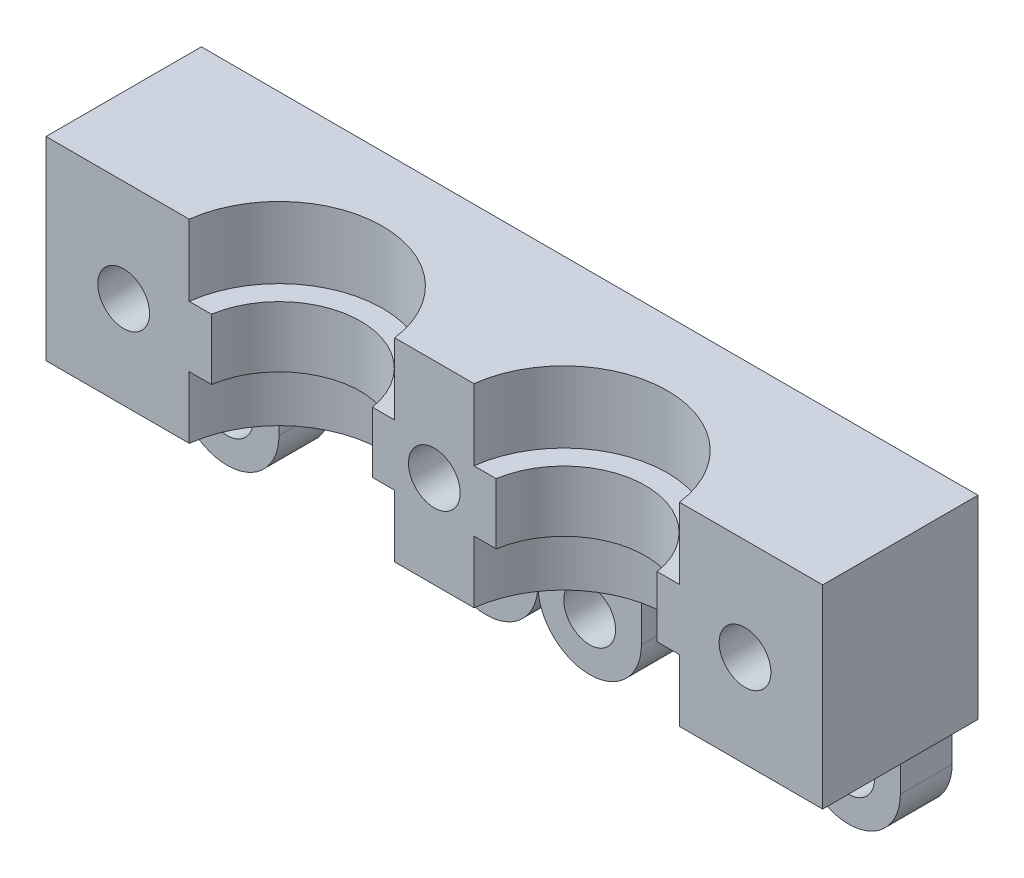
from build123d import *

# Parameters (mm, degrees)
SCHIZZO1_W                   = 60
SCHIZZO1_H                   = 30
ESTRUSIONE_ESTRUSIONE1_DEPTH = 5
SCHIZZO2_W                   = 60
SCHIZZO2_H                   = 8
ESTRUSIONE_ESTRUSIONE2_DEPTH = 20
SCHIZZO3_R                   = 5
TAGLIO_ESTRUSIONE1_DEPTH     = 8
RACCORDO1_R                  = 20
SCHIZZO4_W                   = 60
SCHIZZO4_H                   = 15
ESTRUSIONE_ESTRUSIONE3_DEPTH = 10
SCHIZZO6_R                   = 8
TAGLIO_ESTRUSIONE2_DEPTH     = 15
SCHIZZO8_W                   = 60
SCHIZZO8_H                   = 4.7
ESTRUSIONE_ESTRUSIONE4_DEPTH = 10
SCHIZZO9_R                   = 6.3
TAGLIO_ESTRUSIONE3_DEPTH     = 5
SCHIZZO10_R                  = 2
TAGLIO_ESTRUSIONE4_DEPTH     = 16
SCHIZZO11_W                  = 60
SCHIZZO11_H                  = 8
TAGLIO_ESTRUSIONE5_DEPTH     = 25
SCHIZZO14_W                  = 60
SCHIZZO14_H                  = 5
TAGLIO_ESTRUSIONE7_DEPTH     = 7
SCHIZZO12_R                  = 2
ESTRUSIONE_ESTRUSIONE5_DEPTH = 4
SCHIZZO17_W                  = 60
SCHIZZO17_H                  = 15
TAGLIO_ESTRUSIONE9_DEPTH     = 3


with BuildPart() as part:
    # Schizzo1 → Estrusione-Estrusione1 (new body)
    with BuildSketch(Plane.XY):
        Rectangle(SCHIZZO1_W, SCHIZZO1_H)
    extrude(amount=ESTRUSIONE_ESTRUSIONE1_DEPTH)

    # Schizzo2 → Estrusione-Estrusione2 (add)
    with BuildSketch(Plane.XY.offset(5)):
        with Locations((0, 11)):
            Rectangle(SCHIZZO2_W, SCHIZZO2_H)
    extrude(amount=ESTRUSIONE_ESTRUSIONE2_DEPTH)

    # Schizzo3 → Taglio-Estrusione1 (cut)
    with BuildSketch(Plane(origin=(0, 15, 0), x_dir=(1, 0, 0), z_dir=(0, 1, 0))):
        with Locations((11, -13)):
            Circle(SCHIZZO3_R)
        with Locations((-11, -13)):
            Circle(SCHIZZO3_R)
    extrude(amount=-TAGLIO_ESTRUSIONE1_DEPTH, mode=Mode.SUBTRACT)

    # Raccordo1
    raccordo1_edges = [part.edges().sort_by_distance(p)[0] for p in [
        (30, 11, 25),
        (-30, 11, 25),
    ]]
    fillet(raccordo1_edges, radius=RACCORDO1_R)

    # Schizzo4 → Estrusione-Estrusione3 (add)
    with BuildSketch(Plane.XY.offset(5)):
        with Locations((0, -0.5)):
            Rectangle(SCHIZZO4_W, SCHIZZO4_H)
    extrude(amount=ESTRUSIONE_ESTRUSIONE3_DEPTH)

    # Schizzo6 → Taglio-Estrusione2 (cut)
    with BuildSketch(Plane.XZ.offset(8)):
        with Locations((-11, 13)):
            Circle(SCHIZZO6_R)
        with Locations((11, 13)):
            Circle(SCHIZZO6_R)
    extrude(amount=-TAGLIO_ESTRUSIONE2_DEPTH, mode=Mode.SUBTRACT)

    # Schizzo8 → Estrusione-Estrusione4 (add)
    with BuildSketch(Plane.XY.offset(15)):
        with Locations((0, -0.85)):
            Rectangle(SCHIZZO8_W, SCHIZZO8_H)
    extrude(amount=-ESTRUSIONE_ESTRUSIONE4_DEPTH)

    # Schizzo9 → Taglio-Estrusione3 (cut)
    with BuildSketch(Plane.XZ.offset(3.2)):
        with Locations((-11, 13)):
            Circle(SCHIZZO9_R)
        with Locations((11, 13)):
            Circle(SCHIZZO9_R)
    extrude(amount=-TAGLIO_ESTRUSIONE3_DEPTH, mode=Mode.SUBTRACT)

    # Schizzo10 → Taglio-Estrusione4 (cut, through all)
    with BuildSketch(Plane.XY.offset(15)):
        with Locations((0, -0.85)):
            Circle(SCHIZZO10_R)
        with Locations((24, -0.85)):
            Circle(SCHIZZO10_R)
        with Locations((-24, -0.85)):
            Circle(SCHIZZO10_R)
    extrude(amount=-TAGLIO_ESTRUSIONE4_DEPTH, mode=Mode.SUBTRACT)

    # Schizzo11 → Taglio-Estrusione5 (cut)
    with BuildSketch(Plane(origin=(0, 0, 0), x_dir=(-1, 0, 0), z_dir=(0, 0, -1))):
        with Locations((0, 11)):
            Rectangle(SCHIZZO11_W, SCHIZZO11_H)
    extrude(amount=-TAGLIO_ESTRUSIONE5_DEPTH, mode=Mode.SUBTRACT)

    # Schizzo14 → Taglio-Estrusione7 (cut)
    with BuildSketch(Plane.XZ.offset(15)):
        with Locations((0, 2.5)):
            Rectangle(SCHIZZO14_W, SCHIZZO14_H)
    extrude(amount=-TAGLIO_ESTRUSIONE7_DEPTH, mode=Mode.SUBTRACT)

    # Schizzo12 → Estrusione-Estrusione5 (add)
    with BuildSketch(Plane.XY):
        with BuildLine():
            Line((-28, -12.006435696), (-28, -5.256435696))
            Line((-28, -5.256435696), (28, -5.256435696))
            Line((28, -5.256435696), (28, -12.006435696))
            ThreePointArc((28, -12.006435696), (24, -16.006435696), (20, -12.006435696))
            Line((20, -12.006435696), (20, -8.006435696))
            Line((20, -8.006435696), (8, -8.006435696))
            Line((8, -8.006435696), (8, -12.006435696))
            ThreePointArc((8, -12.006435696), (4, -16.006435696), (0, -12.006435696))
            ThreePointArc((0, -12.006435696), (-4, -16.006435696), (-8, -12.006435696))
            Line((-8, -12.006435696), (-8, -8.006435696))
            Line((-8, -8.006435696), (-20, -8.006435696))
            Line((-20, -8.006435696), (-20, -12.006435696))
            ThreePointArc((-20, -12.006435696), (-24, -16.006435696), (-28, -12.006435696))
        make_face()
        with Locations((24, -12.006435696)):
            Circle(SCHIZZO12_R, mode=Mode.SUBTRACT)
        with Locations((-24, -12.006435696)):
            Circle(SCHIZZO12_R, mode=Mode.SUBTRACT)
        with Locations((4, -12.006435696)):
            Circle(SCHIZZO12_R, mode=Mode.SUBTRACT)
        with Locations((-4, -12.006435696)):
            Circle(SCHIZZO12_R, mode=Mode.SUBTRACT)
    extrude(amount=ESTRUSIONE_ESTRUSIONE5_DEPTH)

    # Schizzo17 → Taglio-Estrusione9 (cut)
    with BuildSketch(Plane.XY.offset(15)):
        with Locations((0, -0.5)):
            Rectangle(SCHIZZO17_W, SCHIZZO17_H)
    extrude(amount=-TAGLIO_ESTRUSIONE9_DEPTH, mode=Mode.SUBTRACT)


solid = part.part
